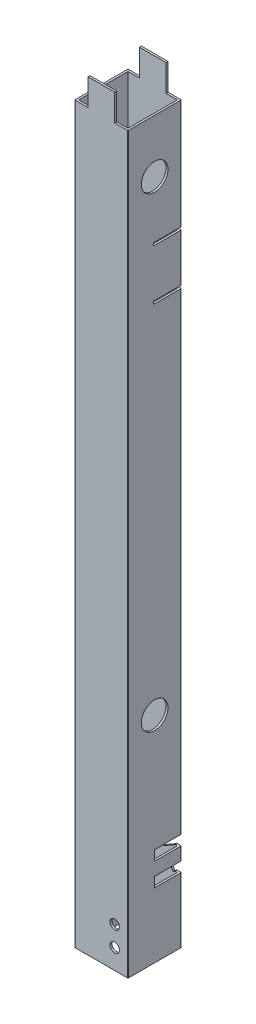
from build123d import *

# Parameters (mm, degrees)
SKETCH1_W           = 37
SKETCH1_H           = 37
BOSS_EXTRUDE1_DEPTH = 571
SKETCH2_W           = 10
SKETCH2_H           = 20
CUT_EXTRUDE1_DEPTH  = 40
SKETCH3_W           = 21
SKETCH3_H           = 2
CUT_EXTRUDE2_DEPTH  = 20
CUT_EXTRUDE3_DEPTH  = 20
SKETCH5_R           = 3.5
CUT_EXTRUDE4_DEPTH  = 10
SKETCH6_R           = 10
CUT_EXTRUDE5_DEPTH  = 574.795259653


with BuildPart() as part:
    # Sketch1 → Boss-Extrude1 (new body)
    with BuildSketch(Plane(origin=(0, 0, 0), x_dir=(1, 0, 0), z_dir=(0, 1, 0))):
        with BuildLine():
            Line((0.5, 0), (39.5, 0))
            ThreePointArc((39.5, 0), (39.853553391, 0.146446609), (40, 0.5))
            Line((40, 0.5), (40, 39.5))
            ThreePointArc((40, 39.5), (39.853553391, 39.853553391), (39.5, 40))
            Line((39.5, 40), (0.5, 40))
            ThreePointArc((0.5, 40), (0.146446609, 39.853553391), (0, 39.5))
            Line((0, 39.5), (0, 0.5))
            ThreePointArc((0, 0.5), (0.146446609, 0.146446609), (0.5, 0))
        make_face()
        with Locations((20, 20)):
            Rectangle(SKETCH1_W, SKETCH1_H, mode=Mode.SUBTRACT)
    extrude(amount=BOSS_EXTRUDE1_DEPTH)

    # Sketch2 → Cut-Extrude1 (cut)
    with BuildSketch(Plane.XY.offset(-40)):
        with Locations((35, 561)):
            Rectangle(SKETCH2_W, SKETCH2_H)
        with Locations((5, 561)):
            Rectangle(SKETCH2_W, SKETCH2_H)
    extrude(amount=CUT_EXTRUDE1_DEPTH, mode=Mode.SUBTRACT)

    # Sketch3 → Cut-Extrude2 (cut)
    with BuildSketch(Plane(origin=(40, 0, 0), x_dir=(0, 0, -1), z_dir=(1, 0, 0))):
        with Locations((29.5, 467.5)):
            Rectangle(SKETCH3_W, SKETCH3_H)
        with Locations((29.5, 429.5)):
            Rectangle(SKETCH3_W, SKETCH3_H)
    extrude(amount=-CUT_EXTRUDE2_DEPTH, mode=Mode.SUBTRACT)

    # Sketch4 → Cut-Extrude3 (cut)
    with BuildSketch(Plane(origin=(0, 0, -40), x_dir=(-1, 0, 0), z_dir=(0, 0, -1))):
        Polygon((-40, 73.59987752), (-37, 73.59987752), (-37, 71.867826713), (-25.659711467, 65.320508076), (-28.159711467, 60.990381057), (-37, 66.094324021), (-40, 66.094324021), align=None)
        Polygon((-40, 56.279369445), (-37, 56.279369445), (-37, 54.547318637), (-32.726698765, 52.080127019), (-35.226698765, 47.75), (-37, 48.773815945), (-40, 48.773815945), align=None)
    extrude(amount=-CUT_EXTRUDE3_DEPTH, mode=Mode.SUBTRACT)

    # Sketch5 → Cut-Extrude4 (cut)
    with BuildSketch(Plane.XY):
        with Locations((30, 15)):
            Circle(SKETCH5_R)
        with Locations((30, 30)):
            Circle(SKETCH5_R)
    extrude(amount=-CUT_EXTRUDE4_DEPTH, mode=Mode.SUBTRACT)

    # Sketch6 → Cut-Extrude5 (cut, through all)
    with BuildSketch(Plane.ZY):
        with Locations((-20, 511)):
            Circle(SKETCH6_R)
        with Locations((-20, 161)):
            Circle(SKETCH6_R)
    extrude(amount=-CUT_EXTRUDE5_DEPTH, mode=Mode.SUBTRACT)


solid = part.part
